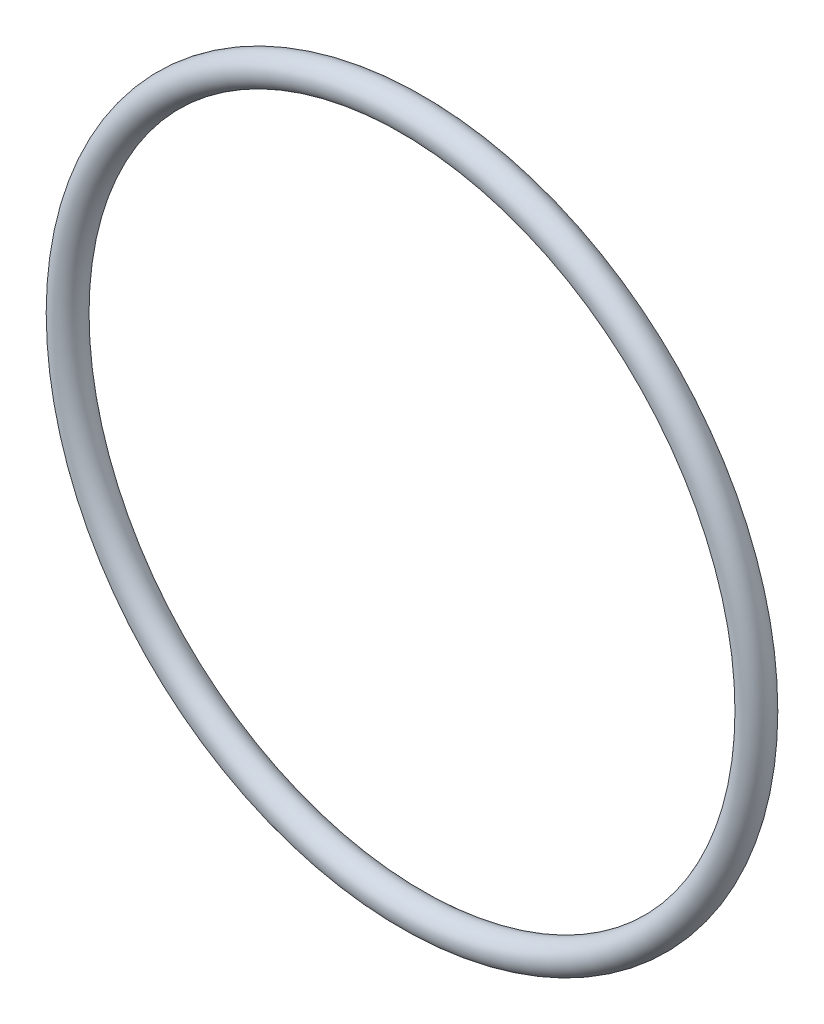
from build123d import *

# Parameters (mm, degrees)
SKETCH1_R = 1.3081


with BuildPart() as part:
    # Sketch1 → Revolve1 (revolve)
    with BuildSketch(Plane(origin=(0, 0, 0), x_dir=(0, -1, 0), z_dir=(1, 0, 0))):
        with Locations((29.718, 0)):
            Circle(SKETCH1_R)
    revolve(axis=Axis((0, 0, 1.3081), (0, 0, -1)))


solid = part.part
